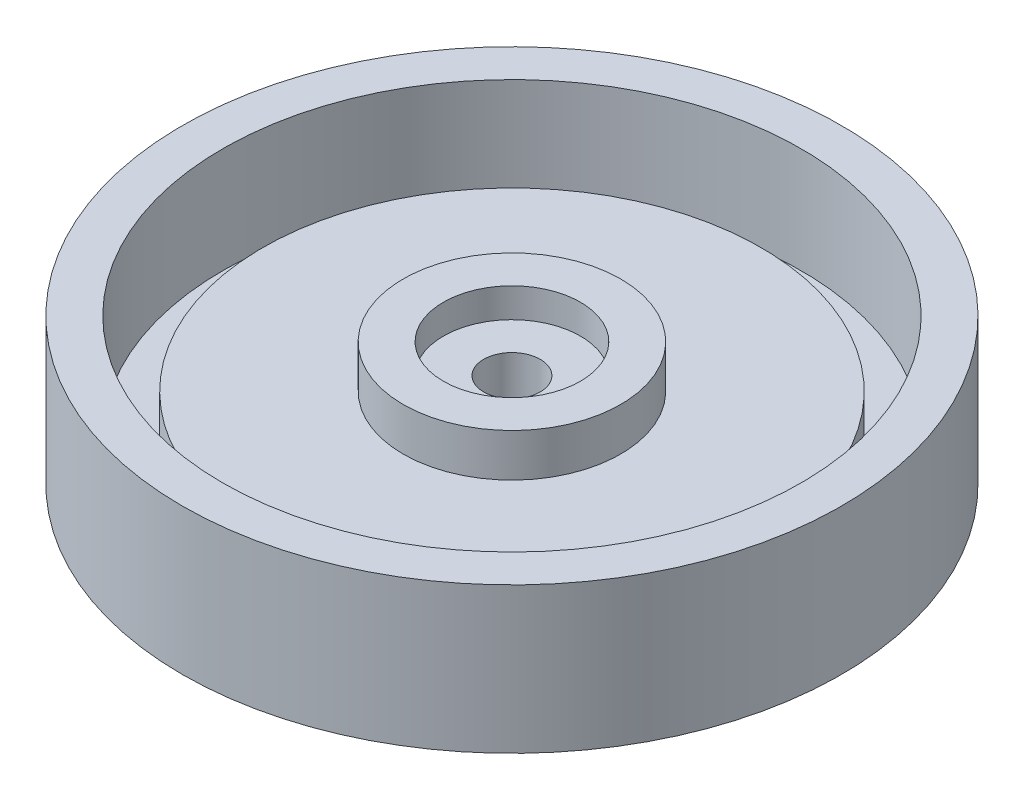
from build123d import *


with BuildPart() as part:
    # Schizzo3 → Rivoluzione1 (revolve)
    with BuildSketch(Plane.XY):
        Polygon((0, -9.36701832), (35.278380685, -9.36701832), (35.278380685, 0), (73.715511564, 0), (73.715511564, 32.63298168), (64.715511564, 32.63298168), (64.715511564, 9), (55.715511564, 9), (55.715511564, 18), (24.325778606, 18), (24.325778606, 27.614456605), (15.325778606, 27.614456605), (15.325778606, 21.045378822), (6.325778606, 21.045378822), (6.325778606, 0), (0, 0), align=None)
    revolve(axis=Axis((0, 108.161755846, 0), (0, -1, 0)))


solid = part.part
